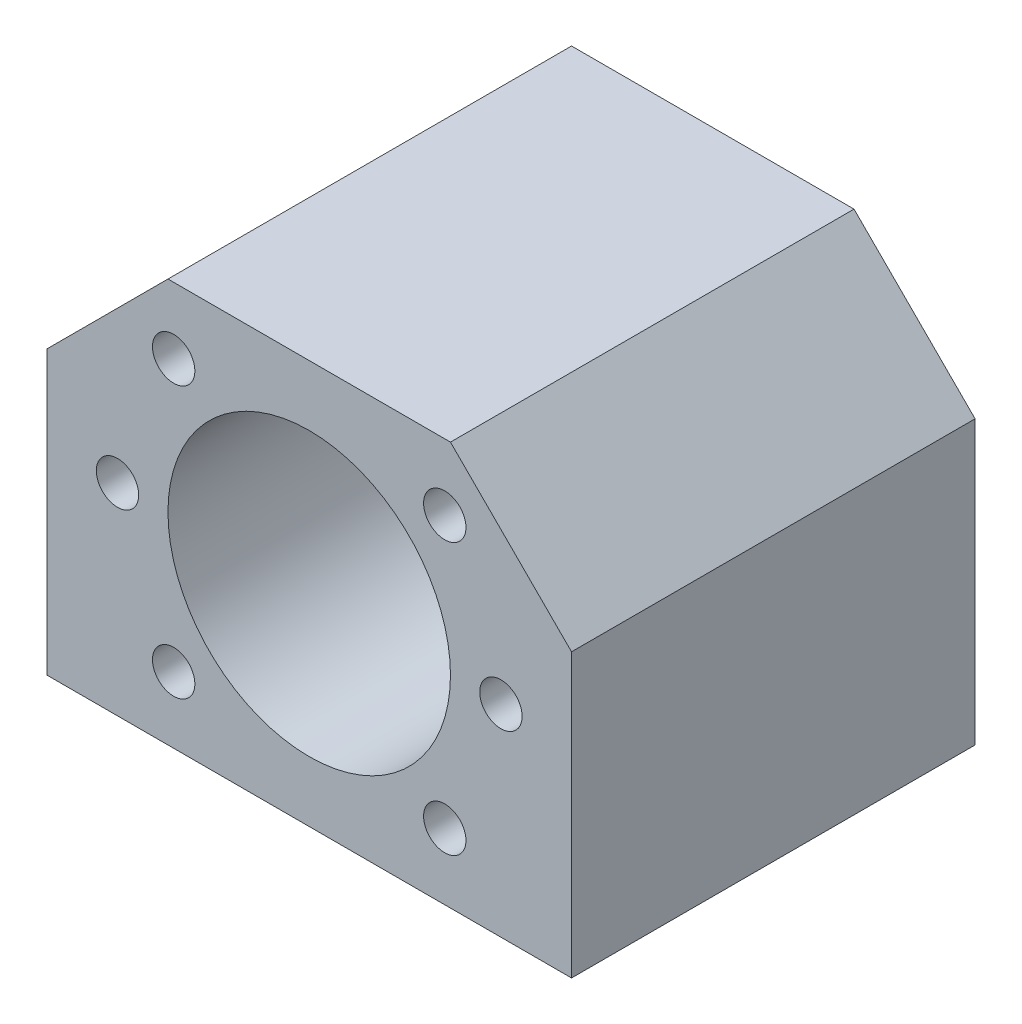
from build123d import *

# Parameters (mm, degrees)
SKETCH1_R                 = 14
BOSS_EXTRUDE1_DEPTH       = 20
M5X0_8_TAPPED_HOLE1_D     = 4.2
M5X0_8_TAPPED_HOLE1_DEPTH = 12.192
M5X0_8_TAPPED_HOLE1_TIP   = 1.2618073
M5X0_8_TAPPED_HOLE2_D     = 4.2
M5X0_8_TAPPED_HOLE2_DEPTH = 12.192
M5X0_8_TAPPED_HOLE2_TIP   = 1.2618073


with BuildPart() as part:
    # Sketch1 → Boss-Extrude1 (new body, symmetric)
    with BuildSketch(Plane.XY):
        Polygon((-14, 20), (-26, 8), (-26, -20), (26, -20), (26, 8), (14, 20), align=None)
        Circle(SKETCH1_R, mode=Mode.SUBTRACT)
    extrude(amount=BOSS_EXTRUDE1_DEPTH, both=True)

    # M5x0.8 Tapped Hole1
    with Locations(Plane.XY.offset(20)):
        with Locations((0, 0), (19, 0), (-19, 0), (-13.435028843, 13.435028843), (13.435028843, -13.435028843), (13.435028843, 13.435028843), (-13.435028843, -13.435028843)):
            Hole(M5X0_8_TAPPED_HOLE1_D / 2, depth=M5X0_8_TAPPED_HOLE1_DEPTH)
            with Locations((0, 0, -(M5X0_8_TAPPED_HOLE1_DEPTH + M5X0_8_TAPPED_HOLE1_TIP / 2))):  # 118° drill point
                Cone(0, M5X0_8_TAPPED_HOLE1_D / 2, M5X0_8_TAPPED_HOLE1_TIP, mode=Mode.SUBTRACT)

    # M5x0.8 Tapped Hole2
    with Locations(Plane(origin=(0, -20, 0), x_dir=(-1, 0, 0), z_dir=(0, -1, 0))):
        with Locations((20, -12), (-20, -12), (-20, 12), (20, 12)):
            Hole(M5X0_8_TAPPED_HOLE2_D / 2, depth=M5X0_8_TAPPED_HOLE2_DEPTH)
            with Locations((0, 0, -(M5X0_8_TAPPED_HOLE2_DEPTH + M5X0_8_TAPPED_HOLE2_TIP / 2))):  # 118° drill point
                Cone(0, M5X0_8_TAPPED_HOLE2_D / 2, M5X0_8_TAPPED_HOLE2_TIP, mode=Mode.SUBTRACT)


solid = part.part
